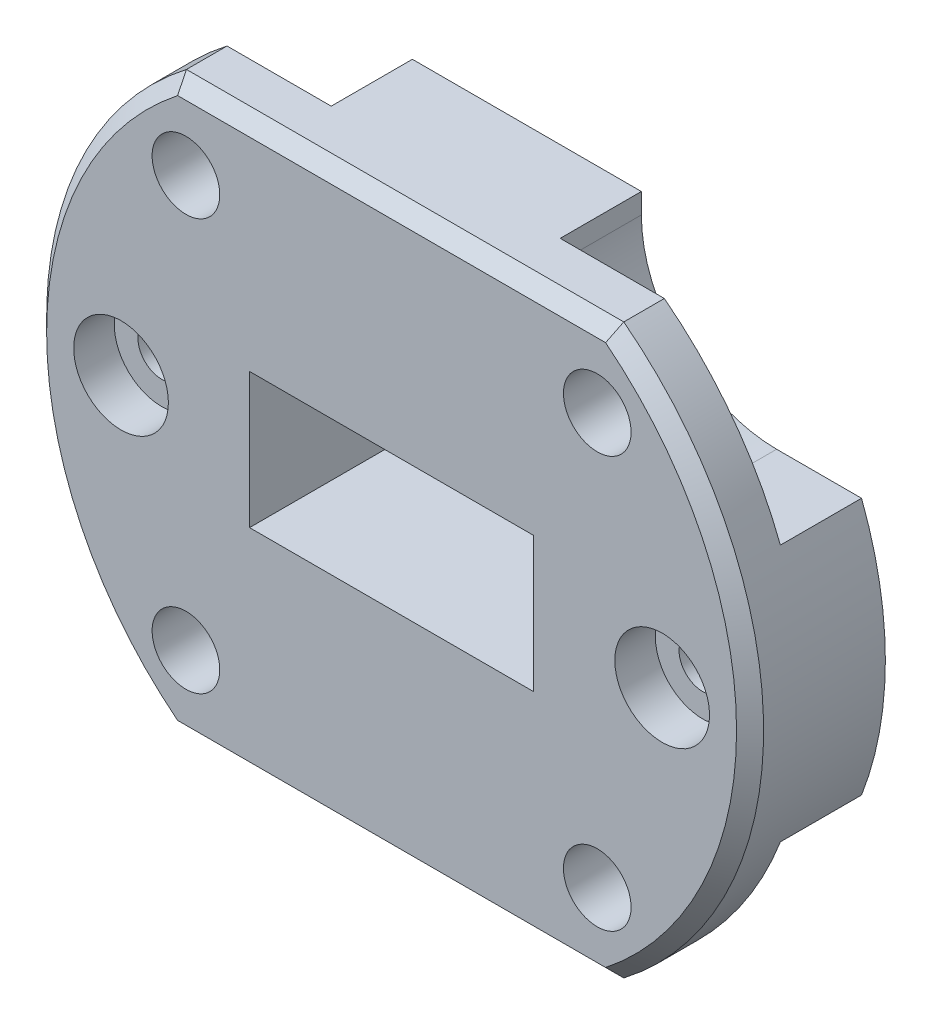
from build123d import *

# Parameters (mm, degrees)
SKETCH_1_R               = 26.5
EXTRUDE_1_DEPTH          = 10
SKETCH_5_R               = 2.5
CUT_EXTRUDE_4_DEPTH      = 11
PATTERN_CIRCULAR_1_COUNT = 4
CHAMFER_1_SIZE           = 1
SKETCH_6_W               = 30
SKETCH_6_H               = 30
SKETCH_8_W               = 21
SKETCH_8_H               = 10
CUT_EXTRUDE_5_DEPTH      = 11
SKETCH_9_R               = 2.5
CUT_EXTRUDE_7_DEPTH      = 6
MIRROR_3_COPY_1_SKETCH_R = 2.5
MIRROR_3_COPY_1_DEPTH    = 6
SKETCH_12_R              = 3.5
CUT_EXTRUDE_8_DEPTH      = 3
SKETCH_13_R              = 1.75
CUT_EXTRUDE_9_DEPTH      = 8
CHAMFER_2_SIZE           = 1


with BuildPart() as part:
    # Эскиз1 → Бобышка-Вытянуть1 (new body)
    with BuildSketch(Plane.XY):
        Circle(SKETCH_1_R)
    extrude(amount=EXTRUDE_1_DEPTH)

    # Эскиз5 → Вырез-Вытянуть4 (cut, through all)
    with BuildSketch(Plane.XY.offset(10)):
        with Locations((-15.202795796, 15.202795796)):
            Circle(SKETCH_5_R)
    cut_extrude_4 = extrude(amount=-CUT_EXTRUDE_4_DEPTH, mode=Mode.SUBTRACT)

    # Круговой массив1: Вырез-Вытянуть4 ×4 about axis
    pattern_circular_1_axis = Axis((0, 0, 0), (0, 0, 1))
    for i in range(1, PATTERN_CIRCULAR_1_COUNT):
        add(cut_extrude_4.rotate(pattern_circular_1_axis, i * 360 / PATTERN_CIRCULAR_1_COUNT), mode=Mode.SUBTRACT)

    # Фаска1
    chamfer_1_edges = [part.edges().sort_by_distance(p)[0] for p in [
        (-26.5, 0, 10),
    ]]
    chamfer(chamfer_1_edges, length=CHAMFER_1_SIZE)

    # Эскиз6 → Вырез-Повернуть1 (revolve, cut)
    with BuildSketch(Plane.XY):
        with Locations((15, 36)):
            Rectangle(SKETCH_6_W, SKETCH_6_H)
    cut_revolve_1 = revolve(axis=Axis((0, 0, 0), (0, 1, 0)), mode=Mode.SUBTRACT)

    # Зеркальное отражение1: Вырез-Повернуть1 across plane
    add(cut_revolve_1.mirror(Plane.ZX), mode=Mode.SUBTRACT)

    # Эскиз8 → Вырез-Вытянуть5 (cut, through all)
    with BuildSketch(Plane.XY.offset(10)):
        Rectangle(SKETCH_8_W, SKETCH_8_H)
    extrude(amount=-CUT_EXTRUDE_5_DEPTH, mode=Mode.SUBTRACT)

    # Эскиз9 → Вырез-Вытянуть7 (cut)
    with BuildSketch(Plane(origin=(0, 0, 0), x_dir=(-1, 0, 0), z_dir=(0, 0, -1))):
        with BuildLine():
            Line((28.463229875, -9.5), (24.738633754, -9.5))
            ThreePointArc((24.738633754, -9.5), (21.243895878, -15.841303227), (16.163229875, -21))
            Line((16.163229875, -21), (8.463229875, -21))
            Line((8.463229875, -21), (8.463229875, -29.5))
            Line((8.463229875, -29.5), (18.463229875, -29.5))
            Line((18.463229875, -29.5), (28.463229875, -29.5))
            Line((28.463229875, -29.5), (28.463229875, -19.5))
            Line((28.463229875, -19.5), (28.463229875, -9.5))
        make_face()
        with BuildLine():
            Line((24.738633754, -9.5), (18.463229875, -9.5))
            ThreePointArc((18.463229875, -9.5), (11.392162063, -12.428932188), (8.463229875, -19.5))
            Line((8.463229875, -19.5), (8.463229875, -21))
            Line((8.463229875, -21), (16.163229875, -21))
            ThreePointArc((16.163229875, -21), (21.243895878, -15.841303227), (24.738633754, -9.5))
        make_face()
        with Locations((15.202795796, -15.202795796)):
            Circle(SKETCH_9_R, mode=Mode.SUBTRACT)
    cut_extrude_7 = extrude(amount=-CUT_EXTRUDE_7_DEPTH, mode=Mode.SUBTRACT)

    # Зеркальное отражение2: Вырез-Вытянуть7 across plane
    add(cut_extrude_7.mirror(Plane.ZX), mode=Mode.SUBTRACT)

    # Зеркальное отражение3: Вырез-Вытянуть7 across plane
    add(cut_extrude_7.mirror(Plane(origin=(0, 0, 0), x_dir=(0, 0, 1), z_dir=(1, 0, 0))), mode=Mode.SUBTRACT)

    # Зеркальное отражение3 copy 1 sketch → Зеркальное отражение3 copy 1 (cut)
    with BuildSketch(Plane(origin=(0, 0, 0), x_dir=(1, 0, 0), z_dir=(0, 0, -1))):
        with BuildLine():
            Line((28.463229875, -9.5), (24.738633754, -9.5))
            ThreePointArc((24.738633754, -9.5), (21.243895878, -15.841303227), (16.163229875, -21))
            Line((16.163229875, -21), (8.463229875, -21))
            Line((8.463229875, -21), (8.463229875, -29.5))
            Line((8.463229875, -29.5), (18.463229875, -29.5))
            Line((18.463229875, -29.5), (28.463229875, -29.5))
            Line((28.463229875, -29.5), (28.463229875, -19.5))
            Line((28.463229875, -19.5), (28.463229875, -9.5))
        make_face()
        with BuildLine():
            Line((24.738633754, -9.5), (18.463229875, -9.5))
            ThreePointArc((18.463229875, -9.5), (11.392162063, -12.428932188), (8.463229875, -19.5))
            Line((8.463229875, -19.5), (8.463229875, -21))
            Line((8.463229875, -21), (16.163229875, -21))
            ThreePointArc((16.163229875, -21), (21.243895878, -15.841303227), (24.738633754, -9.5))
        make_face()
        with Locations((15.202795796, -15.202795796)):
            Circle(MIRROR_3_COPY_1_SKETCH_R, mode=Mode.SUBTRACT)
    extrude(amount=-MIRROR_3_COPY_1_DEPTH, mode=Mode.SUBTRACT)

    # Эскиз12 → Вырез-Вытянуть8 (cut)
    with BuildSketch(Plane.XY.offset(10)):
        with Locations((-20, 0)):
            Circle(SKETCH_12_R)
    cut_extrude_8 = extrude(amount=-CUT_EXTRUDE_8_DEPTH, mode=Mode.SUBTRACT)

    # Эскиз13 → Вырез-Вытянуть9 (cut, through all)
    with BuildSketch(Plane.XY.offset(7)):
        with Locations((-20, 0)):
            Circle(SKETCH_13_R)
    cut_extrude_9 = extrude(amount=-CUT_EXTRUDE_9_DEPTH, mode=Mode.SUBTRACT)

    # Зеркальное отражение4: Вырез-Вытянуть8, Вырез-Вытянуть9 across plane
    add(cut_extrude_8.mirror(Plane(origin=(0, 0, 0), x_dir=(0, 0, 1), z_dir=(1, 0, 0))), mode=Mode.SUBTRACT)
    add(cut_extrude_9.mirror(Plane(origin=(0, 0, 0), x_dir=(0, 0, 1), z_dir=(1, 0, 0))), mode=Mode.SUBTRACT)

    # Фаска2
    chamfer_2_edges = [part.edges().sort_by_distance(p)[0] for p in [
        (0, -21, 10),
        (0, 21, 10),
    ]]
    chamfer(chamfer_2_edges, length=CHAMFER_2_SIZE)


solid = part.part
